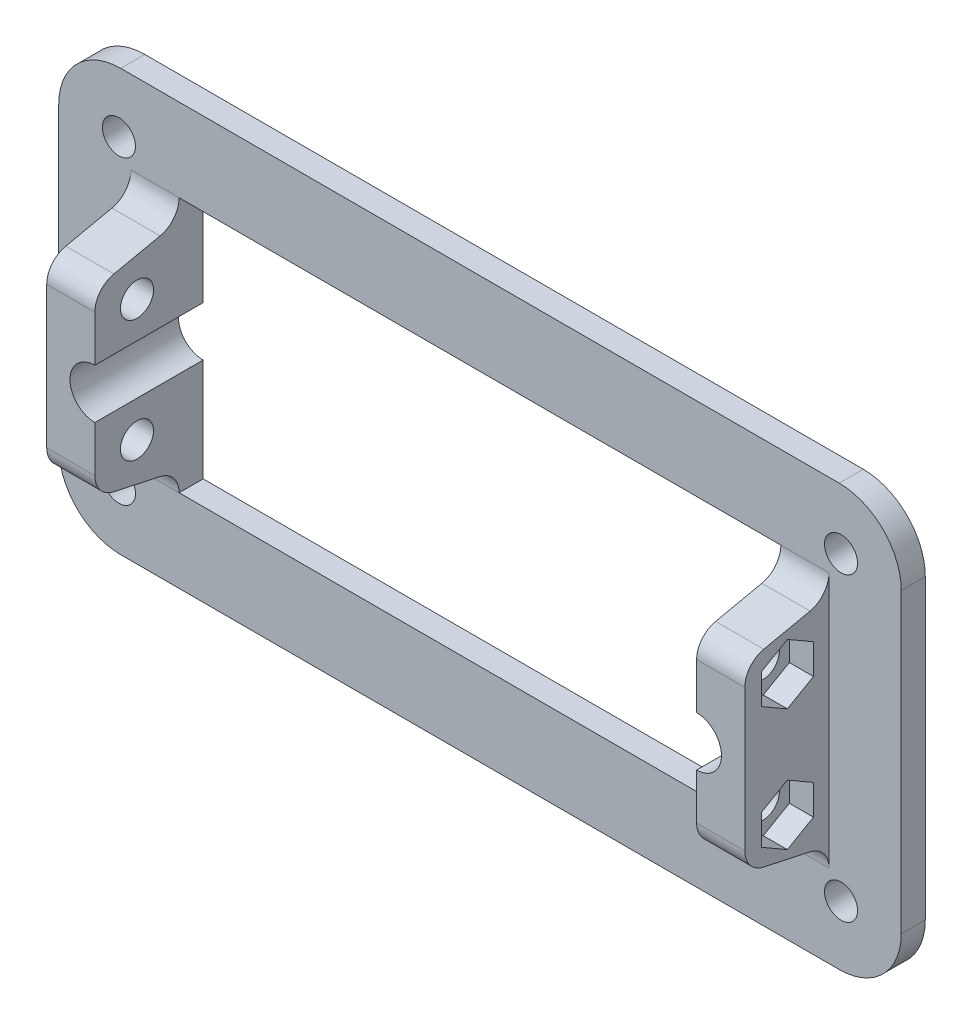
from build123d import *

# Parameters (mm, degrees)
SKETCH1_R           = 2.75
SKETCH1_W           = 100
SKETCH1_H           = 42.46
BOSS_EXTRUDE2_DEPTH = 4
SKETCH4_W           = 8
SKETCH4_H           = 42.46
BOSS_EXTRUDE3_DEPTH = 14
SKETCH5_R           = 4.125
CUT_EXTRUDE2_DEPTH  = 19
SKETCH7_R           = 2.75
CUT_EXTRUDE3_DEPTH  = 4
SKETCH8_R           = 2.75
CUT_EXTRUDE4_DEPTH  = 4
CUT_EXTRUDE8_DEPTH  = 4
CUT_EXTRUDE9_DEPTH  = 4
CUT_EXTRUDE12_DEPTH = 129


with BuildPart() as part:
    # Sketch1 → Boss-Extrude2 (new body)
    with BuildSketch(Plane.XY):
        with BuildLine():
            Line((140, 10.300871341), (140, 59.699128659))
            ThreePointArc((140, 59.699128659), (136.982944636, 66.982944636), (129.699128659, 70))
            Line((129.699128659, 70), (10.300871341, 70))
            ThreePointArc((10.300871341, 70), (3.017055364, 66.982944636), (0, 59.699128659))
            Line((0, 59.699128659), (0, 10.300871341))
            ThreePointArc((0, 10.300871341), (3.017055364, 3.017055364), (10.300871341, 0))
            Line((10.300871341, 0), (129.699128659, 0))
            ThreePointArc((129.699128659, 0), (136.982944636, 3.017055364), (140, 10.300871341))
        make_face()
        with Locations((10, 10)):
            Circle(SKETCH1_R, mode=Mode.SUBTRACT)
        with Locations((130, 10)):
            Circle(SKETCH1_R, mode=Mode.SUBTRACT)
        with Locations((10, 60)):
            Circle(SKETCH1_R, mode=Mode.SUBTRACT)
        with Locations((70, 35)):
            Rectangle(SKETCH1_W, SKETCH1_H, mode=Mode.SUBTRACT)
        with Locations((130, 60)):
            Circle(SKETCH1_R, mode=Mode.SUBTRACT)
    extrude(amount=BOSS_EXTRUDE2_DEPTH)

    # Sketch4 → Boss-Extrude3 (add)
    with BuildSketch(Plane.XY.offset(4)):
        with Locations((16, 35)):
            Rectangle(SKETCH4_W, SKETCH4_H)
        with Locations((124, 35)):
            Rectangle(SKETCH4_W, SKETCH4_H)
    extrude(amount=BOSS_EXTRUDE3_DEPTH)

    # Sketch5 → Cut-Extrude2 (cut, through all)
    with BuildSketch(Plane.XY.offset(18)):
        with Locations((20, 35)):
            Circle(SKETCH5_R)
        with Locations((120, 35)):
            Circle(SKETCH5_R)
    extrude(amount=-CUT_EXTRUDE2_DEPTH, mode=Mode.SUBTRACT)

    # Sketch7 → Cut-Extrude3 (cut)
    with BuildSketch(Plane(origin=(20, 0, 0), x_dir=(0, 0, -1), z_dir=(1, 0, 0))):
        with Locations((-11, 24.875)):
            Circle(SKETCH7_R)
        with Locations((-11, 45.125)):
            Circle(SKETCH7_R)
    extrude(amount=-CUT_EXTRUDE3_DEPTH, mode=Mode.SUBTRACT)

    # Sketch8 → Cut-Extrude4 (cut)
    with BuildSketch(Plane.ZY.offset(-120)):
        with Locations((11, 24.875)):
            Circle(SKETCH8_R)
        with Locations((11, 45.125)):
            Circle(SKETCH8_R)
    extrude(amount=-CUT_EXTRUDE4_DEPTH, mode=Mode.SUBTRACT)

    # Sketch12 → Cut-Extrude8 (cut)
    with BuildSketch(Plane.ZY.offset(-12)):
        Polygon((10.919872981, 19.875), (15.25, 22.375), (15.25, 27.375), (10.919872981, 29.875), (6.589745962, 27.375), (6.589745962, 22.375), align=None)
        Polygon((10.919872981, 40.125), (6.589745962, 42.625), (6.589745962, 47.625), (10.919872981, 50.125), (15.25, 47.625), (15.25, 42.625), align=None)
    extrude(amount=-CUT_EXTRUDE8_DEPTH, mode=Mode.SUBTRACT)

    # Sketch15 → Cut-Extrude9 (cut)
    with BuildSketch(Plane(origin=(128, 0, 0), x_dir=(0, 0, -1), z_dir=(1, 0, 0))):
        Polygon((-10.919872981, 19.875), (-15.25, 22.375), (-15.25, 27.375), (-10.919872981, 29.875), (-6.589745962, 27.375), (-6.589745962, 22.375), align=None)
        Polygon((-15.25, 47.625), (-15.25, 42.625), (-10.919872981, 40.125), (-6.589745962, 42.625), (-6.589745962, 47.625), (-10.919872981, 50.125), align=None)
    extrude(amount=-CUT_EXTRUDE9_DEPTH, mode=Mode.SUBTRACT)

    # Sketch16 → Cut-Extrude12 (cut, through all)
    with BuildSketch(Plane.ZY.offset(-12)):
        with BuildLine():
            Line((18, 13.77), (18, 23.236659765))
            ThreePointArc((18, 23.236659765), (17.110559955, 20.721820453), (14.837791617, 19.325380536))
            Line((14.837791617, 19.325380536), (7.162208383, 17.681279229))
            ThreePointArc((7.162208383, 17.681279229), (4.889440045, 16.284839312), (4, 13.77))
            Line((4, 13.77), (18, 13.77))
        make_face()
        with BuildLine():
            ThreePointArc((4, 56.23), (4.889440045, 53.715160688), (7.162208383, 52.318720771))
            Line((7.162208383, 52.318720771), (14.837791617, 50.674619464))
            ThreePointArc((14.837791617, 50.674619464), (17.110559955, 49.278179547), (18, 46.763340235))
            Line((18, 46.763340235), (18, 56.23))
            Line((18, 56.23), (4, 56.23))
        make_face()
    extrude(amount=-CUT_EXTRUDE12_DEPTH, mode=Mode.SUBTRACT)


solid = part.part
